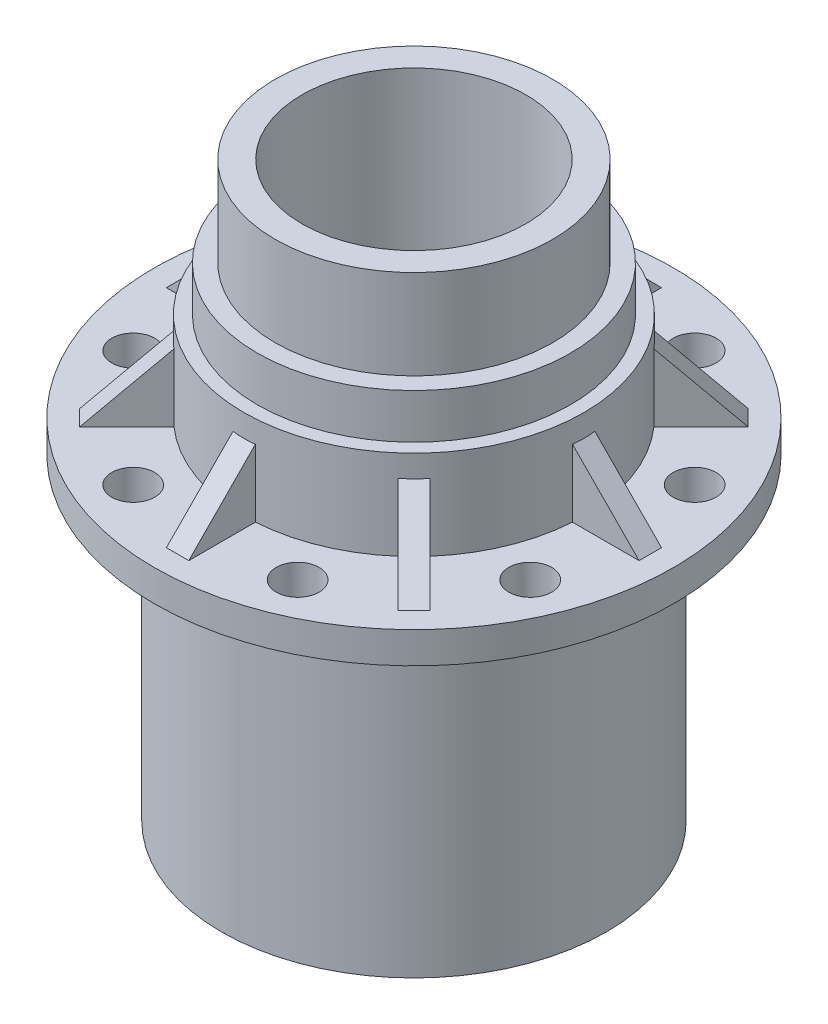
from build123d import *

# Parameters (mm, degrees)
RIB1_REACH         = 292
SKETCH2_WALL_W     = 687.361283212
SKETCH2_WALL_H     = 25
SKETCH3_R          = 24
CUT_EXTRUDE1_DEPTH = 35
CIRPATTERN1_COUNT  = 8
CIRPATTERN2_COUNT  = 8


with BuildPart() as part:
    # Sketch1 → Revolve1 (revolve)
    with BuildSketch(Plane.XY, mode=Mode.PRIVATE) as revolve1_sk:
        Polygon((125, 640), (125, 390), (80, 390), (80, 355), (125, 355), (105, 225), (80, 225), (80, 200), (105, 200), (105, 75), (155, 75), (155, 0), (215, 0), (215, 330), (190, 330), (190, 355), (290, 355), (290, 390), (190, 390), (190, 490), (175, 490), (175, 540), (155, 540), (155, 640), align=None)
    revolve(revolve1_sk.sketch.rotate(Axis((0, 580.752844837, 0), (0, -1, 0)), 90), axis=Axis((0, 580.752844837, 0), (0, -1, 0)))  # turned: the seam where the file's is

    # Sketch2 wall → Rib1 (add, up to next)
    with BuildSketch(Plane(origin=(227, 427.5, 0), x_dir=(-0.70234528, 0.711836433, 0), z_dir=(-0.711836433, -0.70234528, 0)), mode=Mode.PRIVATE) as rib1_sk1:
        Rectangle(SKETCH2_WALL_W, SKETCH2_WALL_H)
    rib1_tool1 = extrude(rib1_sk1.sketch, amount=RIB1_REACH, mode=Mode.PRIVATE) - part.part
    rib1 = rib1_tool1.solids().sort_by_distance((227, 427.5, 0))[0]
    add(rib1)

    # Sketch3 → Cut-Extrude1 (cut)
    with BuildSketch(Plane(origin=(0, 390, 0), x_dir=(1, 0, 0), z_dir=(0, 1, 0))):
        with Locations(Location((221.731087803, 91.844023768, 0), (0, 0, 270))):  # turned: the seam where the file's is
            Circle(SKETCH3_R)
    cut_extrude1 = extrude(amount=-CUT_EXTRUDE1_DEPTH, mode=Mode.SUBTRACT)

    # CirPattern1: Rib1 ×8 about axis
    cirpattern1_axis = Axis((0, 0, 0), (0, 1, 0))
    for i in range(1, CIRPATTERN1_COUNT):
        add(rib1.rotate(cirpattern1_axis, i * 360 / CIRPATTERN1_COUNT))

    # CirPattern2: Cut-Extrude1 ×8 about axis
    cirpattern2_axis = Axis((0, 0, 0), (0, 1, 0))
    for i in range(1, CIRPATTERN2_COUNT):
        add(cut_extrude1.rotate(cirpattern2_axis, i * 360 / CIRPATTERN2_COUNT), mode=Mode.SUBTRACT)


solid = part.part
